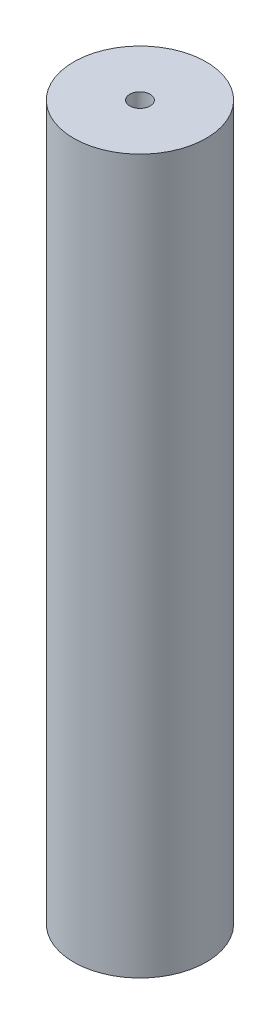
from build123d import *

# Parameters (mm, degrees)
SKETCH1_R           = 6.5
BOSS_EXTRUDE1_DEPTH = 70
SKETCH2_R           = 1
CUT_EXTRUDE1_DEPTH  = 71


with BuildPart() as part:
    # Sketch1 → Boss-Extrude1 (new body)
    with BuildSketch(Plane(origin=(0, 0, 0), x_dir=(1, 0, 0), z_dir=(0, 1, 0))):
        Circle(SKETCH1_R)
    extrude(amount=BOSS_EXTRUDE1_DEPTH)

    # Sketch2 → Cut-Extrude1 (cut, through all)
    with BuildSketch(Plane(origin=(0, 70, 0), x_dir=(1, 0, 0), z_dir=(0, 1, 0))):
        Circle(SKETCH2_R)
    extrude(amount=-CUT_EXTRUDE1_DEPTH, mode=Mode.SUBTRACT)


solid = part.part
